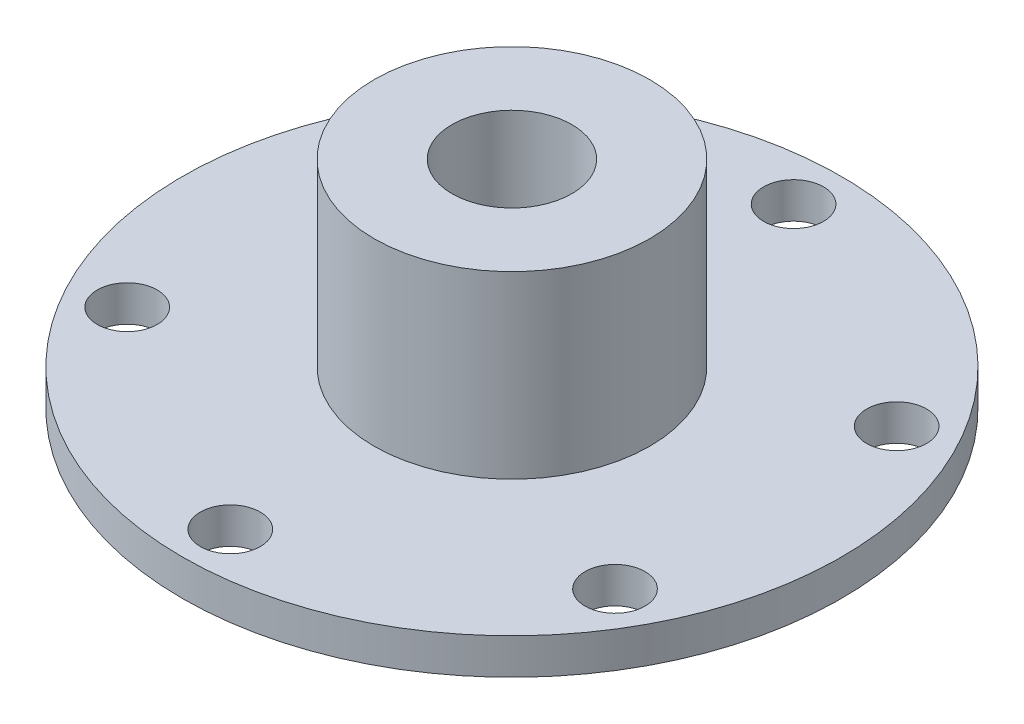
from build123d import *

# Parameters (mm, degrees)
SKETCH1_R           = 27.5
SKETCH1_R_2         = 5
SKETCH1_R_3         = 2.5
BOSS_EXTRUDE1_DEPTH = 3
SKETCH2_R           = 11.5
SKETCH2_R_2         = 5
BOSS_EXTRUDE2_DEPTH = 15


with BuildPart() as part:
    # Sketch1 → Boss-Extrude1 (new body)
    with BuildSketch(Plane(origin=(0, 0, 0), x_dir=(1, 0, 0), z_dir=(0, 1, 0))):
        Circle(SKETCH1_R)
        Circle(SKETCH1_R_2, mode=Mode.SUBTRACT)
        with Locations((0, 23.5)):
            Circle(SKETCH1_R_3, mode=Mode.SUBTRACT)
        with Locations((20.351596989, 11.75)):
            Circle(SKETCH1_R_3, mode=Mode.SUBTRACT)
        with Locations((20.351596989, -11.75)):
            Circle(SKETCH1_R_3, mode=Mode.SUBTRACT)
        with Locations((0, -23.5)):
            Circle(SKETCH1_R_3, mode=Mode.SUBTRACT)
        with Locations((-20.351596989, -11.75)):
            Circle(SKETCH1_R_3, mode=Mode.SUBTRACT)
        with Locations((-20.351596989, 11.75)):
            Circle(SKETCH1_R_3, mode=Mode.SUBTRACT)
    extrude(amount=BOSS_EXTRUDE1_DEPTH)

    # Sketch2 → Boss-Extrude2 (add)
    with BuildSketch(Plane(origin=(0, 3, 0), x_dir=(1, 0, 0), z_dir=(0, 1, 0))):
        Circle(SKETCH2_R)
        Circle(SKETCH2_R_2, mode=Mode.SUBTRACT)
    extrude(amount=BOSS_EXTRUDE2_DEPTH)


solid = part.part
